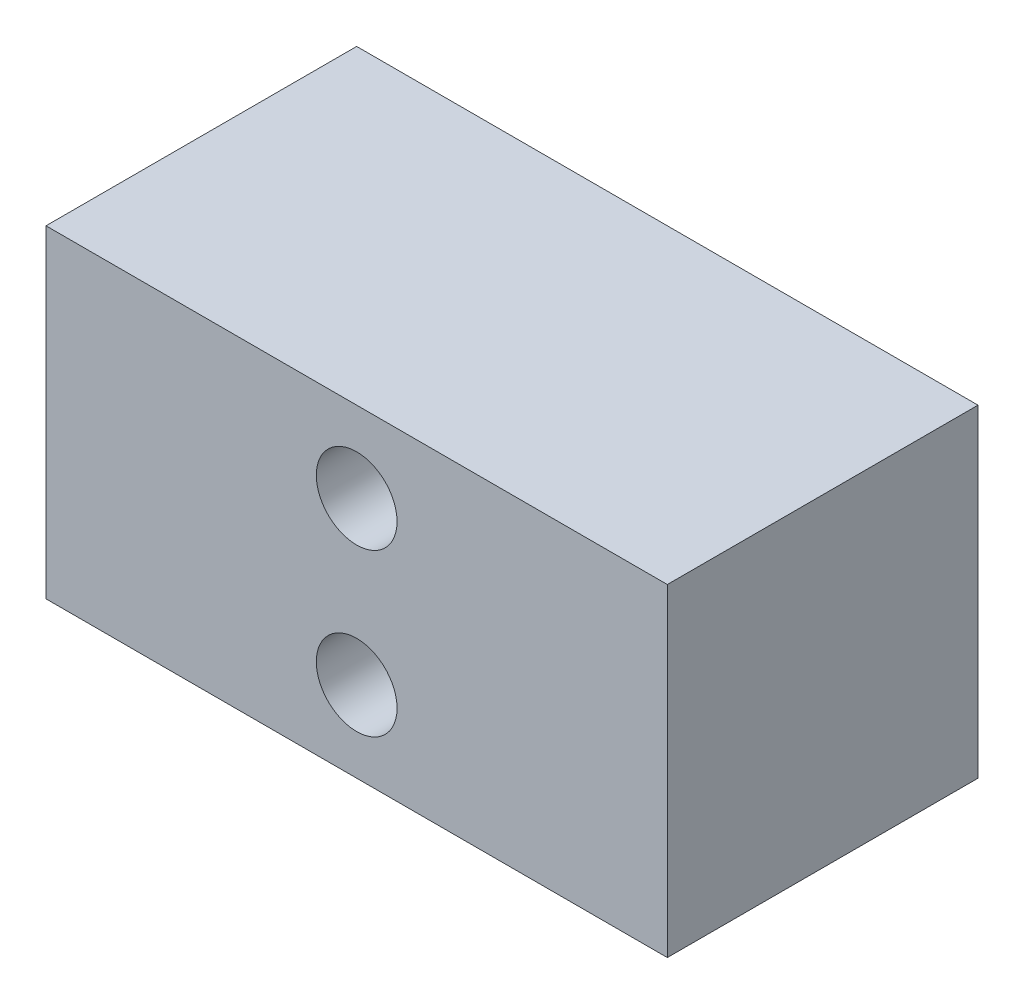
from build123d import *

# Parameters (mm, degrees)
SKETCH1_W           = 50.8
SKETCH1_H           = 26.416
SKETCH1_R           = 3.302
BOSS_EXTRUDE1_DEPTH = 25.4


with BuildPart() as part:
    # Sketch1 → Boss-Extrude1 (new body)
    with BuildSketch(Plane.XY):
        with Locations((25.4, 13.208)):
            Rectangle(SKETCH1_W, SKETCH1_H)
        with Locations((25.4, 19.812)):
            Circle(SKETCH1_R, mode=Mode.SUBTRACT)
        with Locations((25.4, 6.604)):
            Circle(SKETCH1_R, mode=Mode.SUBTRACT)
    extrude(amount=BOSS_EXTRUDE1_DEPTH)


solid = part.part
